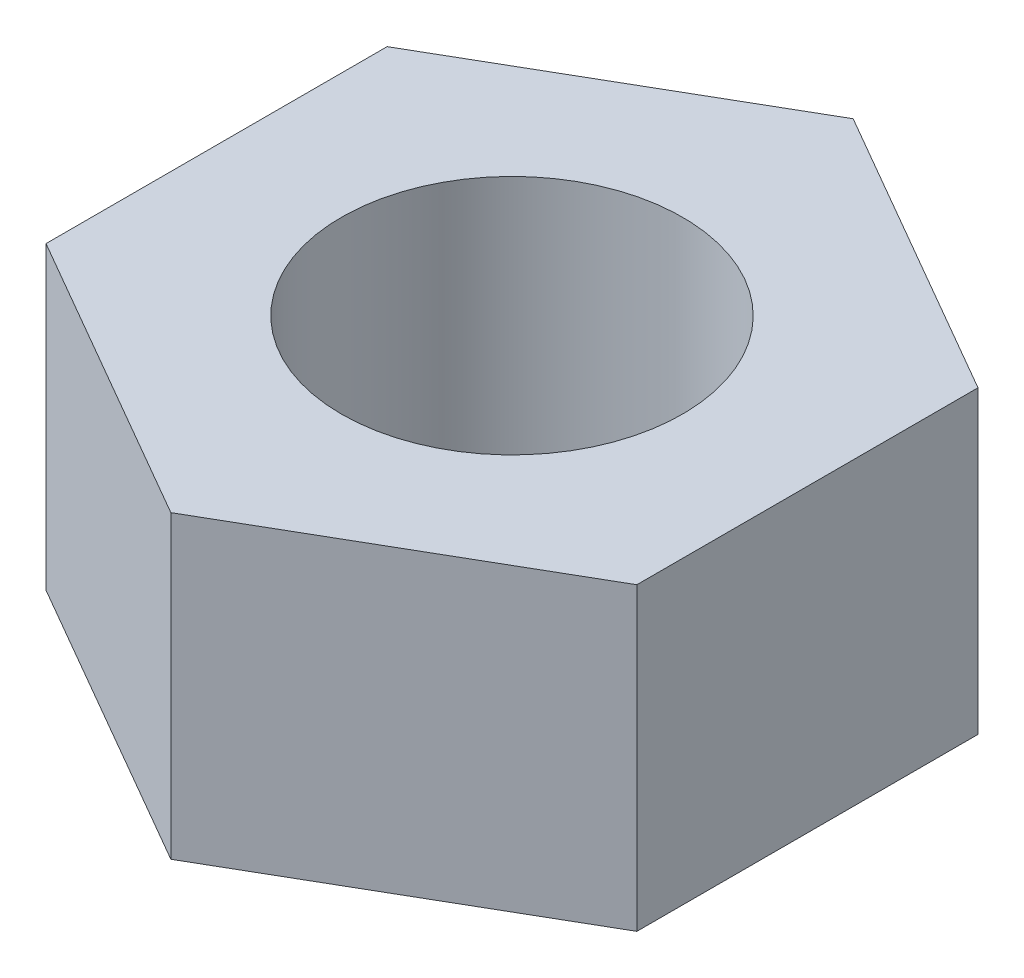
from build123d import *

# Parameters (mm, degrees)
SKETCH1_R           = 3.175
BOSS_EXTRUDE1_DEPTH = 5.588


with BuildPart() as part:
    # Sketch1 → Boss-Extrude1 (new body)
    with BuildSketch(Plane(origin=(0, 0, 0), x_dir=(1, 0, 0), z_dir=(0, 1, 0))):
        Polygon((0, 6.349813731), (-5.4991, 3.174906865), (-5.4991, -3.174906865), (0, -6.349813731), (5.4991, -3.174906865), (5.4991, 3.174906865), align=None)
        Circle(SKETCH1_R, mode=Mode.SUBTRACT)
    extrude(amount=BOSS_EXTRUDE1_DEPTH)


solid = part.part
